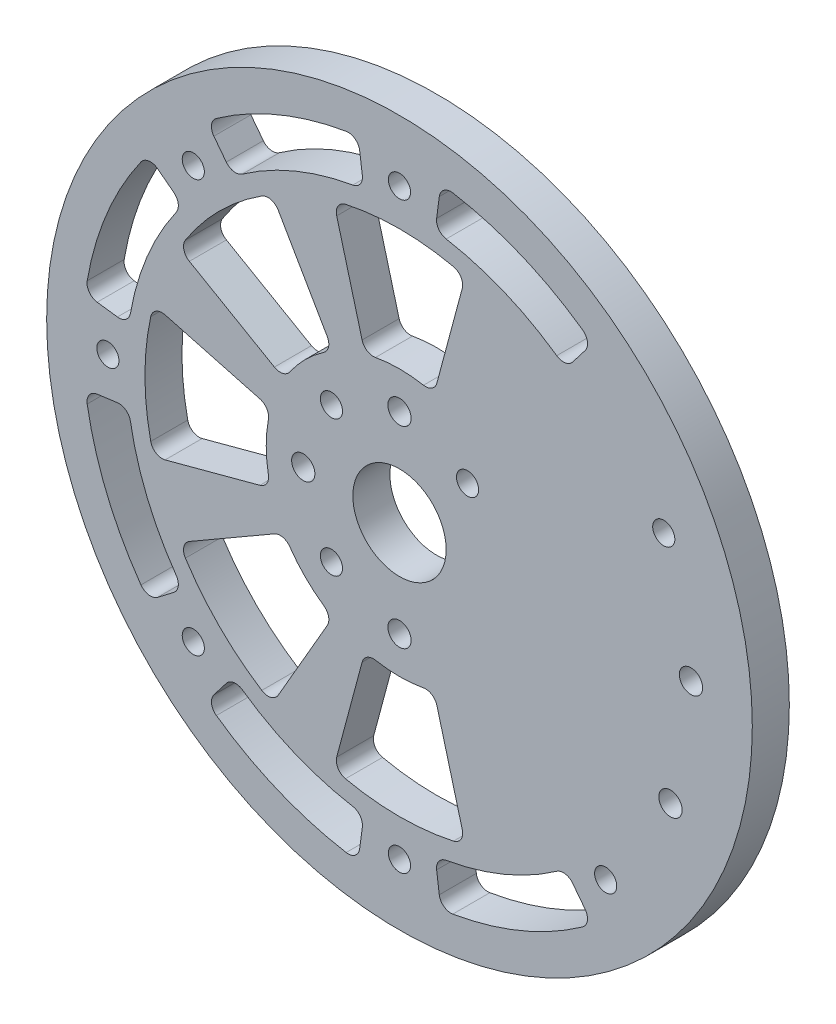
from build123d import *

# Parameters (mm, degrees)
SKETCH1_R                = 60.5
SKETCH1_R_2              = 1.89865
SKETCH1_R_3              = 1.9939
SKETCH1_R_4              = 8
BOSS_EXTRUDE1_DEPTH      = 6.35
CUT_EXTRUDE1_DEPTH       = 7.35
FILLET1_R                = 2
CIRPATTERN1_COUNT        = 8
FILLET1_OF_CIRPATTERN1_R = 2
CUT_EXTRUDE2_DEPTH       = 7.35
FILLET2_R                = 2
CIRPATTERN3_COUNT        = 8
FILLET2_OF_CIRPATTERN3_R = 2
SKETCH4_R                = 4.7625
SKETCH4_R_2              = 1.89865
CUT_EXTRUDE3_DEPTH       = 3.571875


with BuildPart() as part:
    # Sketch1 → Boss-Extrude1 (new body)
    with BuildSketch(Plane.XY):
        Circle(SKETCH1_R)
        with Locations((45.315389352, 21.130913087)):
            Circle(SKETCH1_R_2, mode=Mode.SUBTRACT)
        with Locations((49.978847504, 1.454235937)):
            Circle(SKETCH1_R_3, mode=Mode.SUBTRACT)
        Circle(SKETCH1_R_4, mode=Mode.SUBTRACT)
        with Locations((46.467376211, -18.460307366)):
            Circle(SKETCH1_R_3, mode=Mode.SUBTRACT)
        with Locations((0, -16.5)):
            Circle(SKETCH1_R_3, mode=Mode.SUBTRACT)
        with Locations((0, -50)):
            Circle(SKETCH1_R_2, mode=Mode.SUBTRACT)
        with Locations((-16.5, 0)):
            Circle(SKETCH1_R_3, mode=Mode.SUBTRACT)
        with Locations((-11.66726189, -11.66726189)):
            Circle(SKETCH1_R_2, mode=Mode.SUBTRACT)
        with Locations((0, 16.5)):
            Circle(SKETCH1_R_3, mode=Mode.SUBTRACT)
        with Locations((-11.66726189, 11.66726189)):
            Circle(SKETCH1_R_2, mode=Mode.SUBTRACT)
        with Locations((11.66726189, 11.66726189)):
            Circle(SKETCH1_R_2, mode=Mode.SUBTRACT)
        with Locations((-35.355339059, -35.355339059)):
            Circle(SKETCH1_R_2, mode=Mode.SUBTRACT)
        with Locations((-50, 0)):
            Circle(SKETCH1_R_2, mode=Mode.SUBTRACT)
        with Locations((-35.355339059, 35.355339059)):
            Circle(SKETCH1_R_2, mode=Mode.SUBTRACT)
        with Locations((0, 50)):
            Circle(SKETCH1_R_2, mode=Mode.SUBTRACT)
        with Locations((35.355339059, -35.355339059)):
            Circle(SKETCH1_R_2, mode=Mode.SUBTRACT)
    extrude(amount=BOSS_EXTRUDE1_DEPTH)

    # Sketch2 → Cut-Extrude1 (cut, through all)
    with BuildSketch(Plane.XY.offset(6.35)):
        with BuildLine():
            Line((-22.071405131, 5.914015181), (-42.162662318, 11.297451319))
            ThreePointArc((-42.162662318, 11.297451319), (-43.65, 0), (-42.162662318, -11.297451319))
            Line((-42.162662318, -11.297451319), (-22.071405131, -5.914015181))
            ThreePointArc((-22.071405131, -5.914015181), (-22.85, 0), (-22.071405131, 5.914015181))
        make_face()
    cut_extrude1 = extrude(amount=-CUT_EXTRUDE1_DEPTH, mode=Mode.SUBTRACT)

    # Fillet1
    fillet1_edges = [part.edges().sort_by_distance(p)[0] for p in [
        (-42.162662318, -11.297451319, 3.175),
        (-42.162662318, 11.297451319, 3.175),
        (-22.071405131, 5.914015181, 3.175),
        (-22.071405131, -5.914015181, 3.175),
    ]]
    fillet(fillet1_edges, radius=FILLET1_R)

    # CirPattern1: Cut-Extrude1 ×8 about axis, 3 skipped
    cirpattern1_axis = Axis((0, 0, 0), (0, 0, -1))
    add([cut_extrude1.rotate(cirpattern1_axis, i * 360 / CIRPATTERN1_COUNT) for i in range(1, CIRPATTERN1_COUNT) if i not in (3, 4, 5)], mode=Mode.SUBTRACT)

    # Fillet1 of CirPattern1
    fillet1_of_cirpattern1_edges = [part.edges().sort_by_distance(p)[0] for p in [
        (-37.802008875, 21.825, 3.175),
        (-21.825, 37.802008875, 3.175),
        (-11.425, 19.788680476, 3.175),
        (-19.788680476, 11.425, 3.175),
        (-11.297451319, 42.162662318, 3.175),
        (11.297451319, 42.162662318, 3.175),
        (5.914015181, 22.071405131, 3.175),
        (-5.914015181, 22.071405131, 3.175),
        (11.297451319, -42.162662318, 3.175),
        (-11.297451319, -42.162662318, 3.175),
        (-5.914015181, -22.071405131, 3.175),
        (5.914015181, -22.071405131, 3.175),
        (-21.825, -37.802008875, 3.175),
        (-37.802008875, -21.825, 3.175),
        (-19.788680476, -11.425, 3.175),
        (-11.425, -19.788680476, 3.175),
    ]]
    fillet(fillet1_of_cirpattern1_edges, radius=FILLET1_OF_CIRPATTERN1_R)

    # Sketch3 → Cut-Extrude2 (cut, through all)
    with BuildSketch(Plane.XY.offset(6.35)):
        with BuildLine():
            Line((-43.098920211, 33.070964631), (-37.148770159, 28.505253913))
            ThreePointArc((-37.148770159, 28.505253913), (-43.26065911, 17.91915172), (-46.424405634, 6.111888951))
            Line((-46.424405634, 6.111888951), (-53.860242094, 7.090835392))
            ThreePointArc((-53.860242094, 7.090835392), (-50.189755604, 20.789277463), (-43.098920211, 33.070964631))
        make_face()
    cut_extrude2 = extrude(amount=-CUT_EXTRUDE2_DEPTH, mode=Mode.SUBTRACT)

    # Fillet2
    fillet2_edges = [part.edges().sort_by_distance(p)[0] for p in [
        (-53.860242094, 7.090835392, 3.175),
        (-43.098920211, 33.070964631, 3.175),
        (-37.148770159, 28.505253913, 3.175),
        (-46.424405634, 6.111888951, 3.175),
    ]]
    fillet(fillet2_edges, radius=FILLET2_R)

    # CirPattern3: Cut-Extrude2 ×8 about axis, 2 skipped
    cirpattern3_axis = Axis((0, 0, 0), (0, 0, -1))
    add([cut_extrude2.rotate(cirpattern3_axis, i * 360 / CIRPATTERN3_COUNT) for i in range(1, CIRPATTERN3_COUNT) if i not in (3, 4)], mode=Mode.SUBTRACT)

    # Fillet2 of CirPattern3
    fillet2_of_cirpattern3_edges = [part.edges().sort_by_distance(p)[0] for p in [
        (-33.070964631, 43.098920211, 3.175),
        (-7.090835392, 53.860242094, 3.175),
        (-6.111888951, 46.424405634, 3.175),
        (-28.505253913, 37.148770159, 3.175),
        (7.090835392, 53.860242094, 3.175),
        (33.070964631, 43.098920211, 3.175),
        (28.505253913, 37.148770159, 3.175),
        (6.111888951, 46.424405634, 3.175),
        (33.070964631, -43.098920211, 3.175),
        (7.090835392, -53.860242094, 3.175),
        (6.111888951, -46.424405634, 3.175),
        (28.505253913, -37.148770159, 3.175),
        (-7.090835392, -53.860242094, 3.175),
        (-33.070964631, -43.098920211, 3.175),
        (-28.505253913, -37.148770159, 3.175),
        (-6.111888951, -46.424405634, 3.175),
        (-43.098920211, -33.070964631, 3.175),
        (-53.860242094, -7.090835392, 3.175),
        (-46.424405634, -6.111888951, 3.175),
        (-37.148770159, -28.505253913, 3.175),
    ]]
    fillet(fillet2_of_cirpattern3_edges, radius=FILLET2_OF_CIRPATTERN3_R)

    # Sketch4 → Cut-Extrude3 (cut)
    with BuildSketch(Plane(origin=(0, 0, 0), x_dir=(-1, 0, 0), z_dir=(0, 0, -1))):
        with Locations((0, 50)):
            Circle(SKETCH4_R)
        with Locations((0, 50)):
            Circle(SKETCH4_R_2, mode=Mode.SUBTRACT)
        with Locations((35.355339059, 35.355339059)):
            Circle(SKETCH4_R)
        with Locations((35.355339059, 35.355339059)):
            Circle(SKETCH4_R_2, mode=Mode.SUBTRACT)
        with Locations((50, 0)):
            Circle(SKETCH4_R)
        with Locations((50, 0)):
            Circle(SKETCH4_R_2, mode=Mode.SUBTRACT)
        with Locations((35.355339059, -35.355339059)):
            Circle(SKETCH4_R)
        with Locations((35.355339059, -35.355339059)):
            Circle(SKETCH4_R_2, mode=Mode.SUBTRACT)
        with Locations((0, -50)):
            Circle(SKETCH4_R)
        with Locations((0, -50)):
            Circle(SKETCH4_R_2, mode=Mode.SUBTRACT)
        with Locations((-35.355339059, -35.355339059)):
            Circle(SKETCH4_R)
        with Locations((-35.355339059, -35.355339059)):
            Circle(SKETCH4_R_2, mode=Mode.SUBTRACT)
        with Locations((-45.315389352, 21.130913087)):
            Circle(SKETCH4_R)
        with Locations((-45.315389352, 21.130913087)):
            Circle(SKETCH4_R_2, mode=Mode.SUBTRACT)
    extrude(amount=-CUT_EXTRUDE3_DEPTH, mode=Mode.SUBTRACT)


solid = part.part
